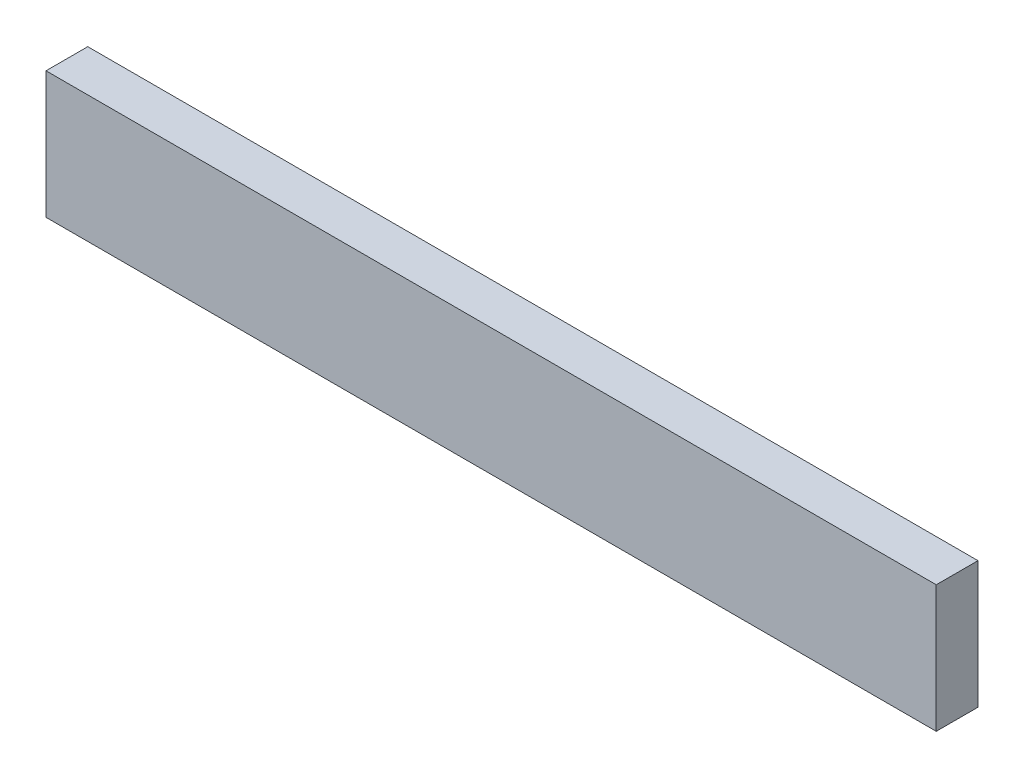
from build123d import *

# Parameters (mm, degrees)
SKETCH1_W           = 1066
SKETCH1_H           = 152
BOSS_EXTRUDE1_DEPTH = 50


with BuildPart() as part:
    # Sketch1 → Boss-Extrude1 (new body)
    with BuildSketch(Plane.XY):
        Rectangle(SKETCH1_W, SKETCH1_H)
    extrude(amount=BOSS_EXTRUDE1_DEPTH)


solid = part.part
